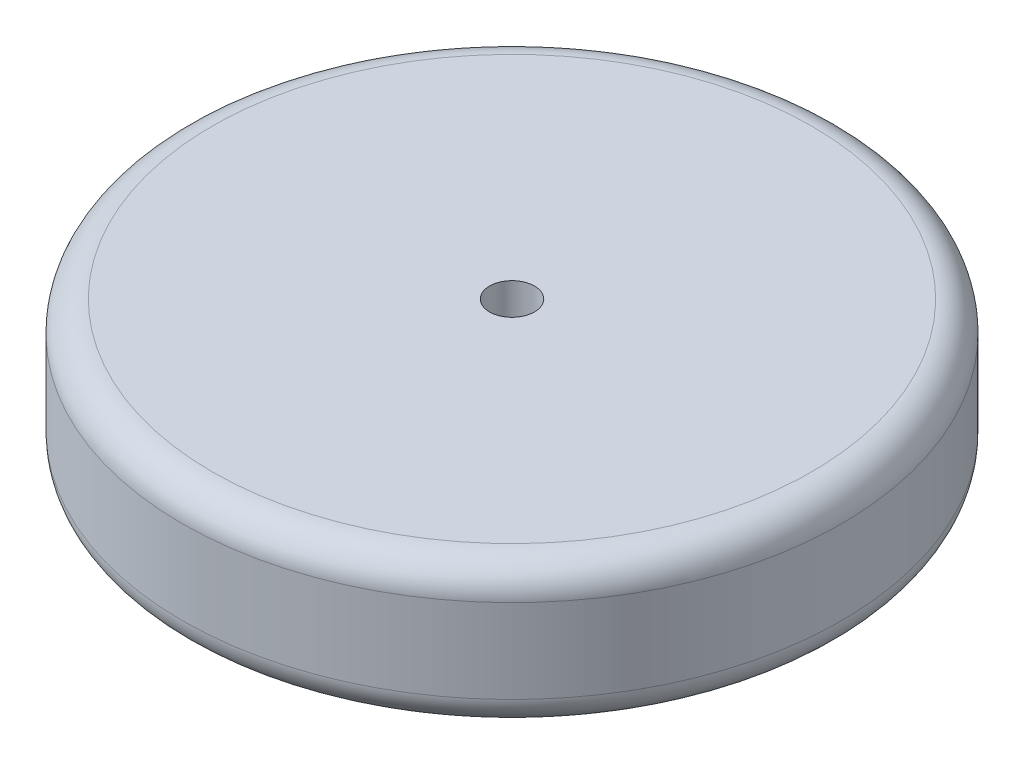
from build123d import *

# Parameters (mm, degrees)
SKETCH1_R           = 69.85
BOSS_EXTRUDE1_DEPTH = 15.24
SKETCH2_R           = 4.7625
CUT_EXTRUDE1_DEPTH  = 30.48
FILLET1_R           = 6.35


with BuildPart() as part:
    # Sketch1 → Boss-Extrude1 (new body, symmetric)
    with BuildSketch(Plane(origin=(0, 0, 0), x_dir=(1, 0, 0), z_dir=(0, 1, 0))):
        Circle(SKETCH1_R)
    extrude(amount=BOSS_EXTRUDE1_DEPTH, both=True)

    # Sketch2 → Cut-Extrude1 (cut)
    with BuildSketch(Plane(origin=(0, 15.24, 0), x_dir=(1, 0, 0), z_dir=(0, 1, 0))):
        Circle(SKETCH2_R)
    extrude(amount=-CUT_EXTRUDE1_DEPTH, mode=Mode.SUBTRACT)

    # Fillet1
    fillet1_edges = [part.edges().sort_by_distance(p)[0] for p in [
        (-69.85, -15.24, 0),
        (-69.85, 15.24, 0),
    ]]
    fillet(fillet1_edges, radius=FILLET1_R)


solid = part.part
